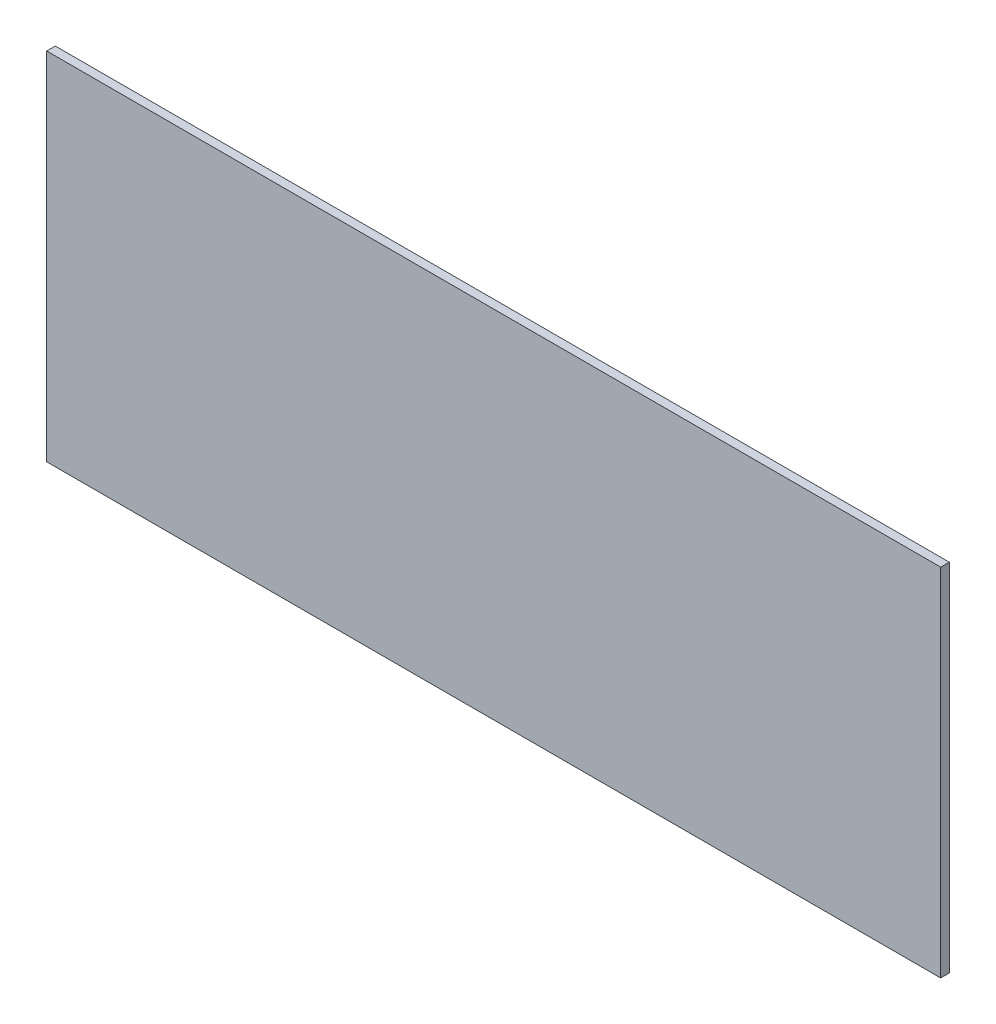
from build123d import *

# Parameters (mm, degrees)
SKETCH1_W           = 208
SKETCH1_H           = 82.78277479
BOSS_EXTRUDE1_DEPTH = 2


with BuildPart() as part:
    # Sketch1 → Boss-Extrude1 (new body)
    with BuildSketch(Plane.XY):
        with Locations((0, 6.461875561)):
            Rectangle(SKETCH1_W, SKETCH1_H)
    extrude(amount=-BOSS_EXTRUDE1_DEPTH)


solid = part.part
